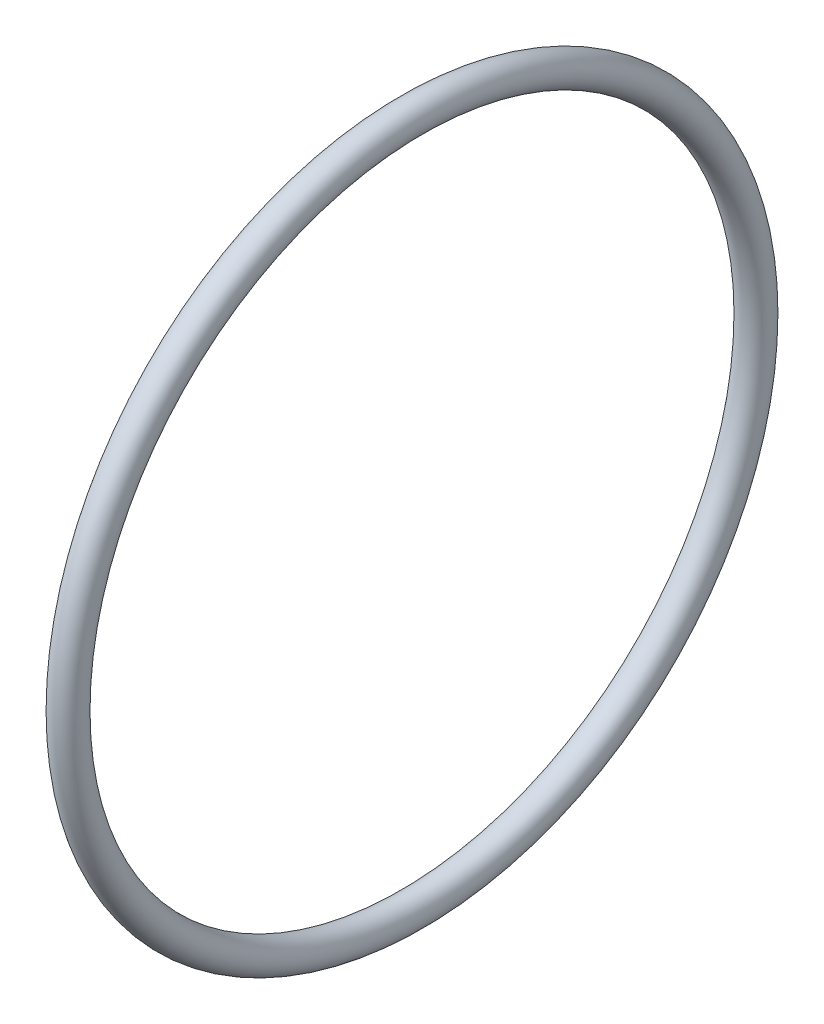
from build123d import *

# Parameters (mm, degrees)
SKETCH2_R = 1.016


with BuildPart() as part:
    # Sketch2 → Revolve3 (revolve)
    with BuildSketch(Plane.XY, mode=Mode.PRIVATE) as revolve3_sk:
        with Locations((2.54, -22.479)):
            Circle(SKETCH2_R)
    revolve(revolve3_sk.sketch.rotate(Axis((-34.684965636, 0, 0), (1, 0, 0)), 270), axis=Axis((-34.684965636, 0, 0), (1, 0, 0)))  # turned: the seam where the file's is


solid = part.part
